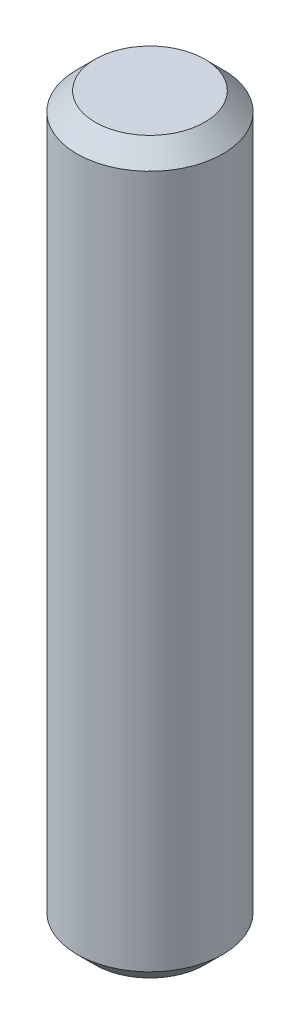
from build123d import *

# Parameters (mm, degrees)
SKETCH1_R           = 0.2
BOSS_EXTRUDE1_DEPTH = 2
CHAMFER1_SIZE       = 0.05


with BuildPart() as part:
    # Sketch1 → Boss-Extrude1 (new body)
    with BuildSketch(Plane(origin=(0, 0, 0), x_dir=(1, 0, 0), z_dir=(0, 1, 0))):
        Circle(SKETCH1_R)
    extrude(amount=BOSS_EXTRUDE1_DEPTH)

    # Chamfer1
    chamfer1_edges = [part.edges().sort_by_distance(p)[0] for p in [
        (-0.2, 0, 0),
        (-0.2, 2, 0),
    ]]
    chamfer(chamfer1_edges, length=CHAMFER1_SIZE)


solid = part.part
